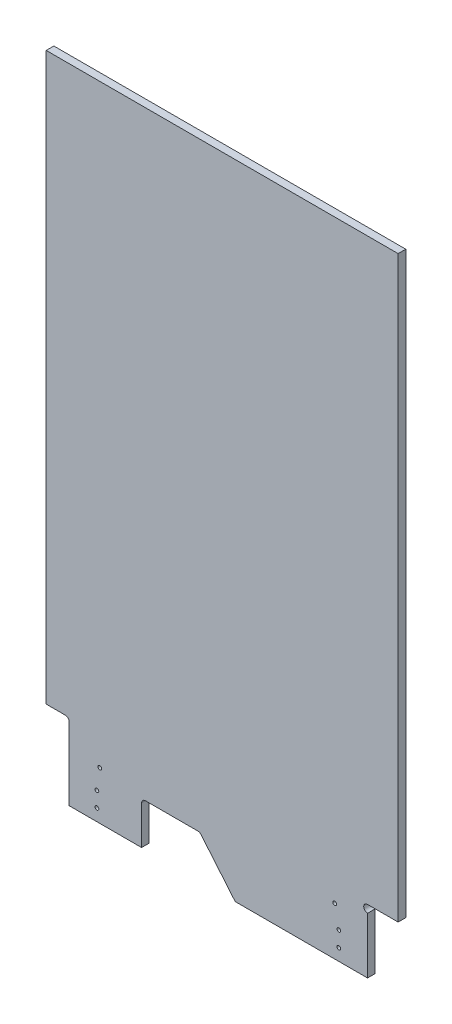
from build123d import *

# Parameters (mm, degrees)
PLAYFIELD_BLANK_W         = 584.2
PLAYFIELD_BLANK_H         = 1066.8
PLAYFIELD_THICKNESS_DEPTH = 12.7
SKETCH3_R                 = 3.1115
CUT_EXTRUDE1_DEPTH        = 12.7
CUT_EXTRUDE2_DEPTH        = 12.7
CUT_EXTRUDE3_DEPTH        = 12.7
CUT_EXTRUDE4_DEPTH        = 12.7


with BuildPart() as part:
    # Playfield_Blank → Playfield_Thickness (new body)
    with BuildSketch(Plane.XY):
        with Locations((292.1, 533.4)):
            Rectangle(PLAYFIELD_BLANK_W, PLAYFIELD_BLANK_H)
    extrude(amount=-PLAYFIELD_THICKNESS_DEPTH)

    # Sketch3 → Cut-Extrude1 (cut)
    with BuildSketch(Plane.XY):
        with Locations((84.136105728, 19.812)):
            Circle(SKETCH3_R)
        with Locations((84.136105728, 45.212)):
            Circle(SKETCH3_R)
        with Locations((88.898605728, 80.137)):
            Circle(SKETCH3_R)
        with Locations((485.773605728, 19.812)):
            Circle(SKETCH3_R)
        with Locations((485.773605728, 45.212)):
            Circle(SKETCH3_R)
        with Locations((478.788605728, 80.137)):
            Circle(SKETCH3_R)
    extrude(amount=-CUT_EXTRUDE1_DEPTH, mode=Mode.SUBTRACT)

    # Sketch4 → Cut-Extrude2 (cut)
    with BuildSketch(Plane.XY):
        with BuildLine():
            Line((0, 127), (31.75, 127))
            ThreePointArc((31.75, 127), (36.240128061, 125.140128061), (38.1, 120.65))
            Line((38.1, 120.65), (38.1, 0))
            Line((38.1, 0), (0, 0))
            Line((0, 0), (0, 127))
        make_face()
    extrude(amount=-CUT_EXTRUDE2_DEPTH, mode=Mode.SUBTRACT)

    # Sketch5 → Cut-Extrude3 (cut)
    with BuildSketch(Plane.XY):
        with BuildLine():
            Line((584.2, 105.791), (533.4, 105.791))
            ThreePointArc((533.4, 105.791), (527.05, 99.441), (533.4, 93.091))
            Line((533.4, 93.091), (533.4, 0))
            Line((533.4, 0), (584.2, 0))
            Line((584.2, 0), (584.2, 105.791))
        make_face()
    extrude(amount=-CUT_EXTRUDE3_DEPTH, mode=Mode.SUBTRACT)

    # Sketch7 → Cut-Extrude4 (cut)
    with BuildSketch(Plane.XY):
        with BuildLine():
            Line((158.326337108, 0), (158.326337108, 64.094614523))
            ThreePointArc((158.326337108, 64.094614523), (160.186209048, 68.584742584), (164.676337108, 70.444614523))
            Line((164.676337108, 70.444614523), (251.90120893, 70.444614523))
            ThreePointArc((251.90120893, 70.444614523), (254.5903795, 69.847080224), (256.773448763, 68.16693315))
            Line((256.773448763, 68.16693315), (313.748778564, 0))
            Line((313.748778564, 0), (158.326337108, 0))
        make_face()
    extrude(amount=-CUT_EXTRUDE4_DEPTH, mode=Mode.SUBTRACT)


solid = part.part
